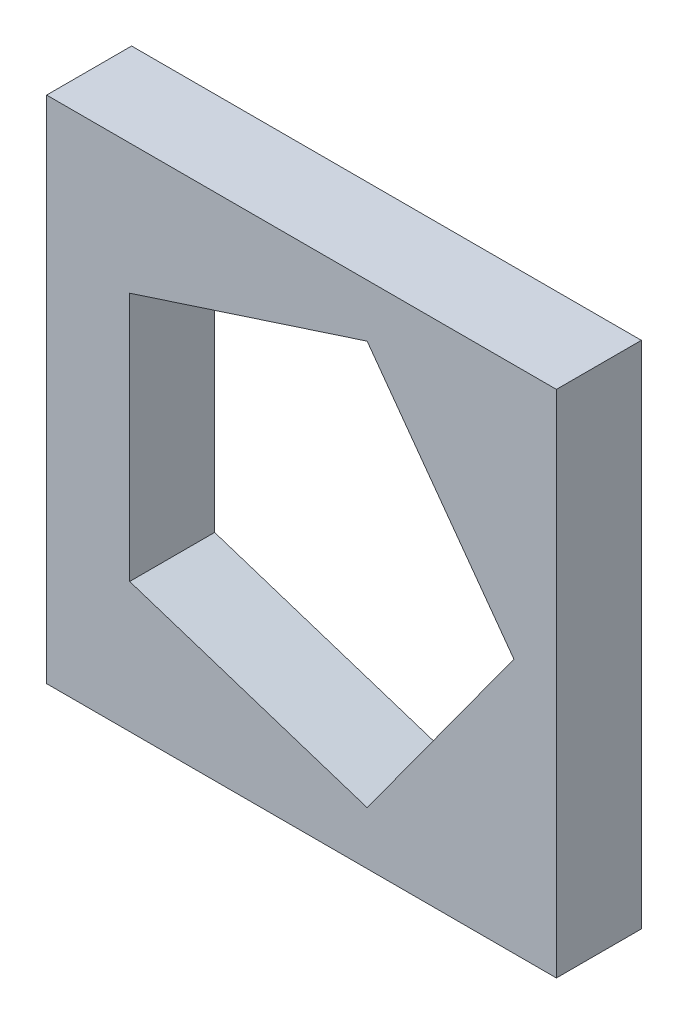
from build123d import *

# Parameters (mm, degrees)
SCHIZZO1_W                   = 60
SCHIZZO1_H                   = 60
ESTRUSIONE_ESTRUSIONE1_DEPTH = 10


with BuildPart() as part:
    # Schizzo1 → Estrusione-Estrusione1 (new body)
    with BuildSketch(Plane.XY):
        Rectangle(SCHIZZO1_W, SCHIZZO1_H)
        Polygon((7.725424859, -23.776412907), (25, 0), (7.725424859, 23.776412907), (-20.225424859, 14.694631307), (-20.225424859, -14.694631307), align=None, mode=Mode.SUBTRACT)
    extrude(amount=ESTRUSIONE_ESTRUSIONE1_DEPTH)


solid = part.part
